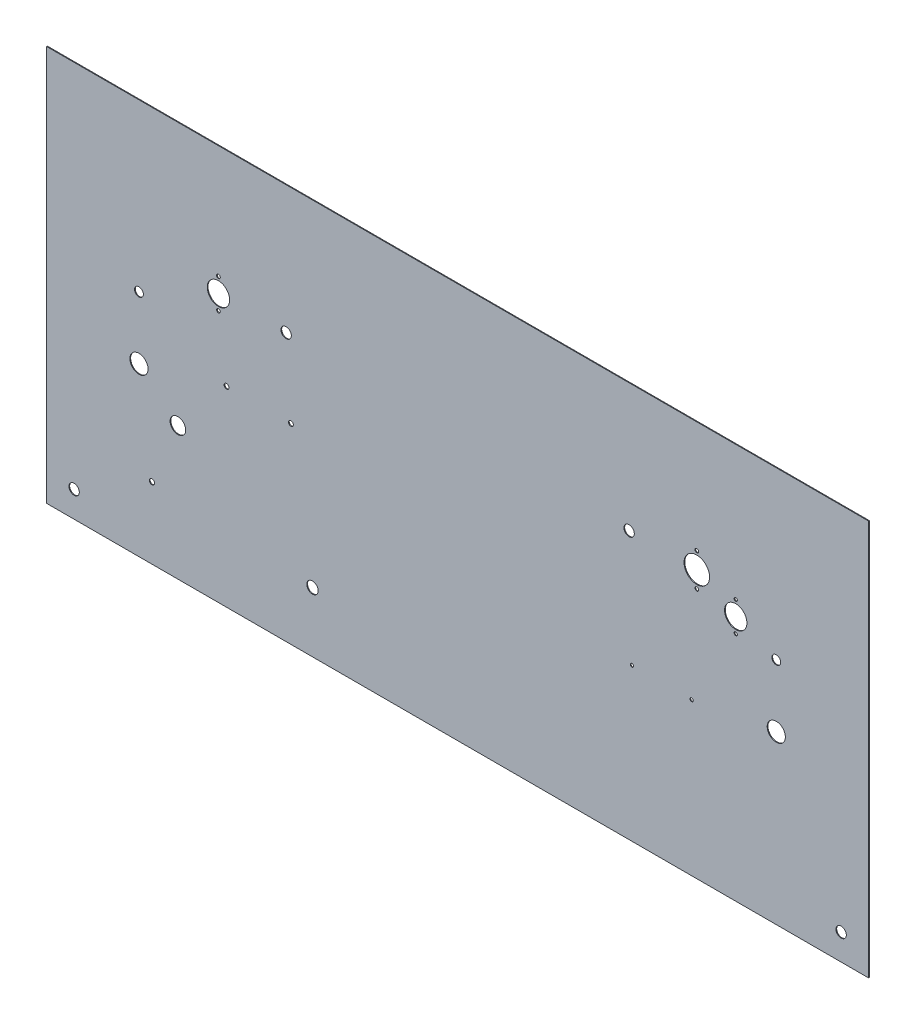
from build123d import *

# Parameters (mm, degrees)
BASE_SKETCH_W                              = 804.8625
BASE_SKETCH_H                              = 387.35
BASE_SKETCH_R                              = 5.08
BASE_W_MOUNT_HOLES_DEPTH                   = 0.7366
THROTTLE_AND_CHOKE_CUTOUT_SKETCH_R         = 8.89
THROTTLE_AND_CHOKE_CUTOUT_SKETCH_R_2       = 4.318
THROTTLE_AND_CHOKE_CUTOUTS_DEPTH           = 1.7366
STARTER_RELAY_MOUNT_SKETCH_R               = 2.38125
STARTER_RELAY_MOUNT_DEPTH                  = 1.7366
OIL_PRESSURE_SENDER_CLAMP_MOUNT_SKETCH_R   = 2.54
OIL_PRESSURE_SENDER_CLAMP_MOUNT_DEPTH      = 1.7366
STARTER_POWER_CUTOUT_SKETCH_R              = 5.588
STARTER_POWER_CUTOUT_DEPTH                 = 1.7366
FUEL_RETURN_CUTOUT_SKETCH_R                = 7.62
FUEL_RETURN_CUTOUT_DEPTH                   = 1.7366
BRAKE_MASTER_CYL_MOUNT_SKETCH_R            = 1.6256
BRAKE_MASTER_CYL_MOUNT_DEPTH               = 1.7366
CUTOUT_AS012_INSTRUMENTATION_RIGHT_S_R     = 10.94994
CUTOUT_AS012_INSTRUMENTATION_RIGHT_S_R_2   = 1.8034
CUTOUT_AS012_INSTRUMENTATION_RIGHT_DEPTH   = 1.7366
CUTOUT_AS014_TACH_AND_CDI_ENABLE_2_R       = 12.4968
CUTOUT_AS014_TACH_AND_CDI_ENABLE_2_R_2     = 1.8034
CUTOUT_AS014_TACH_AND_CDI_ENABLES_LE_DEPTH = 1.7366
CUTOUT_AS012_INSTRUMENTATION_LEFT_SK_R     = 10.94994
CUTOUT_AS012_INSTRUMENTATION_LEFT_SK_R_2   = 1.6002
CUTOUT_AS012_INSTRUMENTATION_LEFT_DEPTH    = 1.7366


with BuildPart() as part:
    # Base Sketch → Base w Mount Holes (new body)
    with BuildSketch(Plane.XY):
        with Locations((375.44375, 168.275)):
            Rectangle(BASE_SKETCH_W, BASE_SKETCH_H)
        Circle(BASE_SKETCH_R, mode=Mode.SUBTRACT)
        with Locations((750.8875, 0)):
            Circle(BASE_SKETCH_R, mode=Mode.SUBTRACT)
        with Locations((207.565625, 236.5375)):
            Circle(BASE_SKETCH_R, mode=Mode.SUBTRACT)
        with Locations((543.321875, 236.5375)):
            Circle(BASE_SKETCH_R, mode=Mode.SUBTRACT)
    extrude(amount=BASE_W_MOUNT_HOLES_DEPTH)

    # Throttle and Choke Cutout Sketch → Throttle and Choke Cutouts (cut, through all)
    with BuildSketch(Plane.XY.offset(0.7366)):
        with Locations((63.5, 138.1125)):
            Circle(THROTTLE_AND_CHOKE_CUTOUT_SKETCH_R)
        with Locations((63.5, 199.0725)):
            Circle(THROTTLE_AND_CHOKE_CUTOUT_SKETCH_R_2)
        with Locations((687.3875, 199.0725)):
            Circle(THROTTLE_AND_CHOKE_CUTOUT_SKETCH_R_2)
        with Locations((687.3875, 138.1125)):
            Circle(THROTTLE_AND_CHOKE_CUTOUT_SKETCH_R)
    extrude(amount=-THROTTLE_AND_CHOKE_CUTOUTS_DEPTH, mode=Mode.SUBTRACT)

    # Starter Relay Mount Sketch → Starter Relay Mount (cut, through all)
    with BuildSketch(Plane.XY.offset(0.7366)):
        with Locations((149.225, 161.925)):
            Circle(STARTER_RELAY_MOUNT_SKETCH_R)
        with Locations((212.217, 161.925)):
            Circle(STARTER_RELAY_MOUNT_SKETCH_R)
    extrude(amount=-STARTER_RELAY_MOUNT_DEPTH, mode=Mode.SUBTRACT)

    # Oil Pressure Sender Clamp Mount Sketch → Oil Pressure Sender Clamp Mount (cut, through all)
    with BuildSketch(Plane.XY.offset(0.7366)):
        with Locations((76.2, 44.45)):
            Circle(OIL_PRESSURE_SENDER_CLAMP_MOUNT_SKETCH_R)
    extrude(amount=-OIL_PRESSURE_SENDER_CLAMP_MOUNT_DEPTH, mode=Mode.SUBTRACT)

    # Starter Power Cutout Sketch → Starter Power Cutout (cut, through all)
    with BuildSketch(Plane.XY.offset(0.7366)):
        with Locations((233.3625, 33.3375)):
            Circle(STARTER_POWER_CUTOUT_SKETCH_R)
    extrude(amount=-STARTER_POWER_CUTOUT_DEPTH, mode=Mode.SUBTRACT)

    # Fuel Return Cutout Sketch → Fuel Return Cutout (cut, through all)
    with BuildSketch(Plane.XY.offset(0.7366)):
        with Locations((101.6, 104.775)):
            Circle(FUEL_RETURN_CUTOUT_SKETCH_R)
    extrude(amount=-FUEL_RETURN_CUTOUT_DEPTH, mode=Mode.SUBTRACT)

    # Brake Master Cyl Mount Sketch → Brake Master Cyl Mount (cut, through all)
    with BuildSketch(Plane.XY.offset(0.7366)):
        with Locations((546.1, 123.825)):
            Circle(BRAKE_MASTER_CYL_MOUNT_SKETCH_R)
        with Locations((604.52, 123.825)):
            Circle(BRAKE_MASTER_CYL_MOUNT_SKETCH_R)
    extrude(amount=-BRAKE_MASTER_CYL_MOUNT_DEPTH, mode=Mode.SUBTRACT)

    # Cutout - AS012 - Instrumentation Right Sketch → Cutout - AS012 - Instrumentation Right (cut, through all)
    with BuildSketch(Plane.XY.offset(0.7366)):
        with Locations((141.2875, 236.5375)):
            Circle(CUTOUT_AS012_INSTRUMENTATION_RIGHT_S_R)
        with Locations((141.2875, 221.98711)):
            Circle(CUTOUT_AS012_INSTRUMENTATION_RIGHT_S_R_2)
        with Locations((141.2875, 251.08789)):
            Circle(CUTOUT_AS012_INSTRUMENTATION_RIGHT_S_R_2)
    extrude(amount=-CUTOUT_AS012_INSTRUMENTATION_RIGHT_DEPTH, mode=Mode.SUBTRACT)

    # Cutout - AS014 - Tach and CDI Enable 2 → Cutout - AS014 - Tach and CDI Enables Le (cut, through all)
    with BuildSketch(Plane.XY.offset(0.7366)):
        with Locations((609.6, 236.5375)):
            Circle(CUTOUT_AS014_TACH_AND_CDI_ENABLE_2_R)
        with Locations((609.6, 252.78715)):
            Circle(CUTOUT_AS014_TACH_AND_CDI_ENABLE_2_R_2)
        with Locations((609.6, 220.28785)):
            Circle(CUTOUT_AS014_TACH_AND_CDI_ENABLE_2_R_2)
    extrude(amount=-CUTOUT_AS014_TACH_AND_CDI_ENABLES_LE_DEPTH, mode=Mode.SUBTRACT)

    # Cutout - AS012 - Instrumentation Left Sketch → Cutout - AS012 - Instrumentation Left (cut, through all)
    with BuildSketch(Plane.XY.offset(0.7366)):
        with Locations((647.7, 215.9)):
            Circle(CUTOUT_AS012_INSTRUMENTATION_LEFT_SK_R)
        with Locations((647.7, 230.45039)):
            Circle(CUTOUT_AS012_INSTRUMENTATION_LEFT_SK_R_2)
        with Locations((647.7, 201.34961)):
            Circle(CUTOUT_AS012_INSTRUMENTATION_LEFT_SK_R_2)
    extrude(amount=-CUTOUT_AS012_INSTRUMENTATION_LEFT_DEPTH, mode=Mode.SUBTRACT)


solid = part.part
